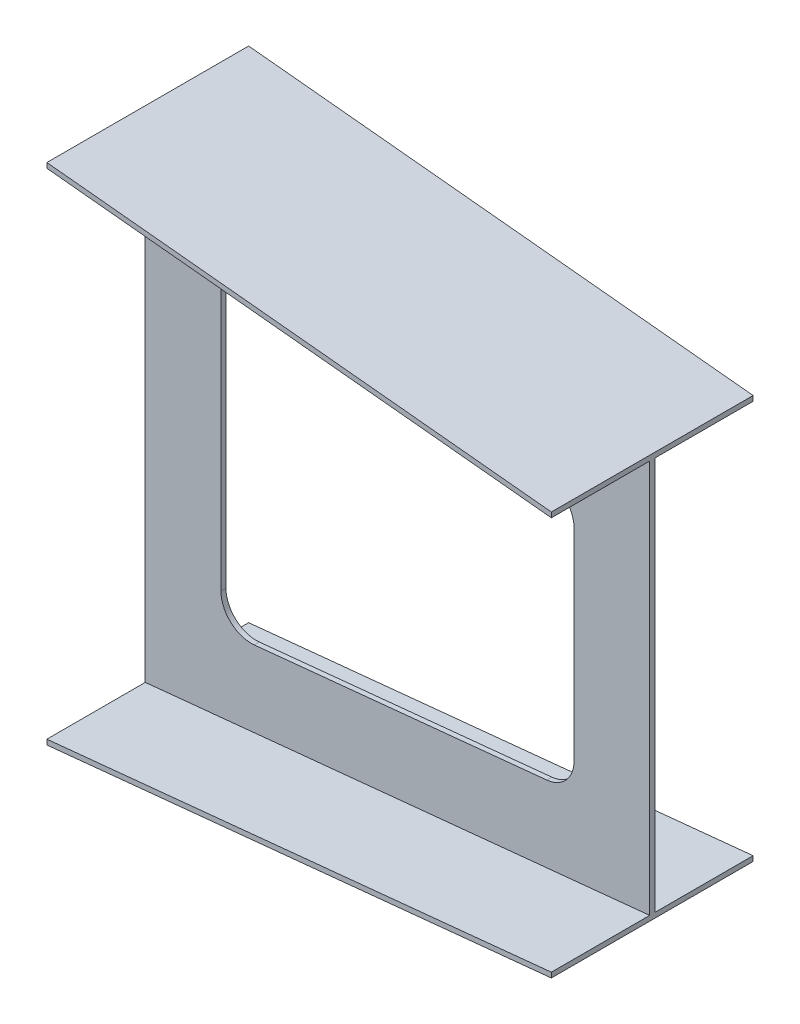
from build123d import *

# Parameters (mm, degrees)
CUT_EXTRUDE1_DEPTH = 10


with BuildPart() as part:
    # Sketch1 → Loft4 section 0
    with BuildSketch(Plane(origin=(0, 0, 0), x_dir=(0, 0, -1), z_dir=(1, 0, 0))):
        Polygon((-205, 500), (195, 500), (195, 490), (0, 490), (0, -490), (195, -490), (195, -500), (-205, -500), (-205, -490), (-10, -490), (-10, 490), (-205, 490), align=None)
    # Sketch4 → Loft4 section 1
    with BuildSketch(Plane(origin=(1000, 0, -1000), x_dir=(0, 0, 1), z_dir=(-1, 0, 0))):
        Polygon((805, 400), (1205, 400), (1205, 390), (1010, 390), (1010, -390), (1205, -390), (1205, -400), (805, -400), (805, -390), (1000, -390), (1000, 390), (805, 390), align=None)
    loft()

    # Sketch6 → Cut-Extrude1 (cut)
    with BuildSketch(Plane.XY.offset(10)):
        with BuildLine():
            Line((215.970223141, -317.654843369), (795.970223141, -259.654843369))
            ThreePointArc((795.970223141, -259.654843369), (834.487152013, -240.212931202), (850, -199.952611956))
            Line((850, -199.952611956), (850, 199.952611956))
            ThreePointArc((850, 199.952611956), (834.487152013, 240.212931202), (795.970223141, 259.654843369))
            Line((795.970223141, 259.654843369), (215.970223141, 317.654843369))
            ThreePointArc((215.970223141, 317.654843369), (169.739680754, 302.43976397), (150, 257.952611956))
            Line((150, 257.952611956), (150, -257.952611956))
            ThreePointArc((150, -257.952611956), (169.739680754, -302.43976397), (215.970223141, -317.654843369))
        make_face()
    extrude(amount=-CUT_EXTRUDE1_DEPTH, mode=Mode.SUBTRACT)


solid = part.part
